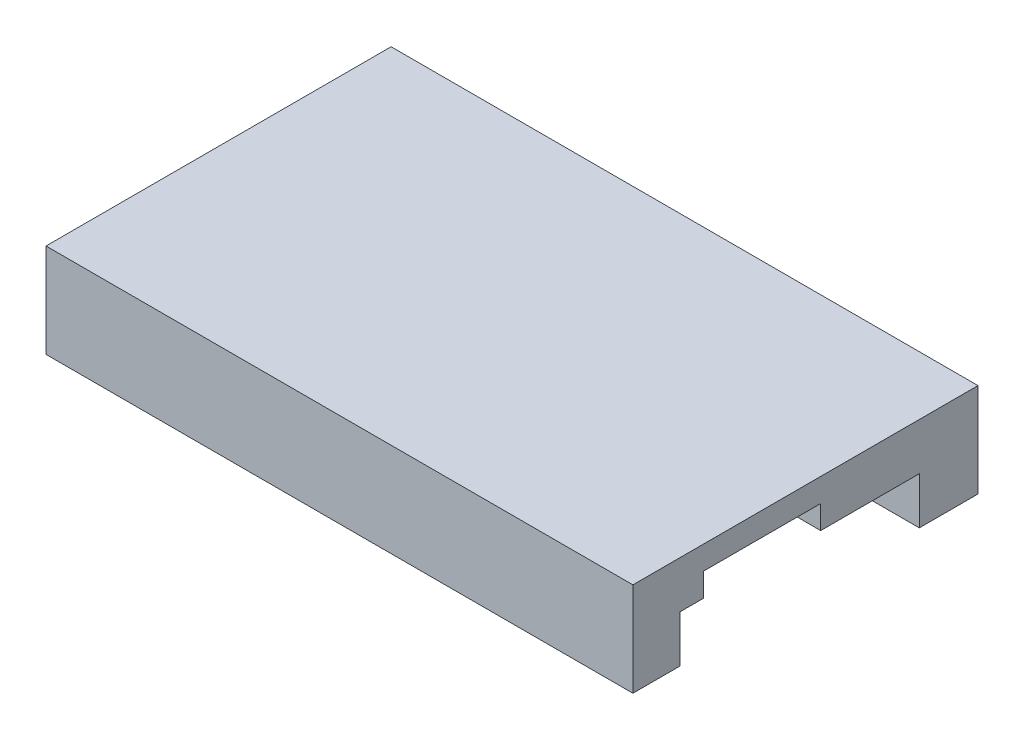
from build123d import *

# Parameters (mm, degrees)
SKETCH1_W           = 25
SKETCH1_H           = 14.7
BOSS_EXTRUDE1_DEPTH = 1
SKETCH2_W           = 5
SKETCH2_H           = 7.3
CUT_EXTRUDE1_DEPTH  = 1
SKETCH3_W           = 7.5
SKETCH3_H           = 5
CUT_EXTRUDE2_DEPTH  = 1
BOSS_EXTRUDE2_DEPTH = 1
SKETCH9_W           = 25
SKETCH9_H           = 14.7
BOSS_EXTRUDE3_DEPTH = 1
SKETCH11_W          = 22.5
SKETCH11_H          = 1
SKETCH11_W_2        = 2.5
SKETCH11_H_2        = 1.5
BOSS_EXTRUDE5_DEPTH = 1


with BuildPart() as part:
    # Sketch1 → Boss-Extrude1 (new body)
    with BuildSketch(Plane(origin=(0, 0, 0), x_dir=(1, 0, 0), z_dir=(0, 1, 0))):
        with Locations((-29.985488774, 13.606547542)):
            Rectangle(SKETCH1_W, SKETCH1_H)
    extrude(amount=BOSS_EXTRUDE1_DEPTH)

    # Sketch2 → Cut-Extrude1 (cut)
    with BuildSketch(Plane(origin=(0, 1, 0), x_dir=(1, 0, 0), z_dir=(0, 1, 0))):
        with Locations((-39.985488774, 14.606547542)):
            Rectangle(SKETCH2_W, SKETCH2_H)
    extrude(amount=-CUT_EXTRUDE1_DEPTH, mode=Mode.SUBTRACT)

    # Sketch3 → Cut-Extrude2 (cut)
    with BuildSketch(Plane(origin=(0, 1, 0), x_dir=(1, 0, 0), z_dir=(0, 1, 0))):
        with Locations((-21.235488774, 11.756547542)):
            Rectangle(SKETCH3_W, SKETCH3_H)
    extrude(amount=-CUT_EXTRUDE2_DEPTH, mode=Mode.SUBTRACT)

    # Sketch4 → Boss-Extrude2 (add)
    with BuildSketch(Plane.XZ):
        Polygon((-42.485488774, -6.256547542), (-42.485488774, -7.756547542), (-20.485488774, -7.756547542), (-20.485488774, -8.256547542), (-17.485488774, -8.256547542), (-17.485488774, -6.256547542), align=None)
        Polygon((-20.485488774, -19.456547542), (-42.485488774, -19.456547542), (-42.485488774, -20.956547542), (-17.485488774, -20.956547542), (-17.485488774, -18.456547542), (-20.485488774, -18.456547542), align=None)
    extrude(amount=BOSS_EXTRUDE2_DEPTH)

    # Sketch9 → Boss-Extrude3 (add)
    with BuildSketch(Plane(origin=(0, 1, 0), x_dir=(1, 0, 0), z_dir=(0, 1, 0))):
        with Locations((-29.985488774, 13.606547542)):
            Rectangle(SKETCH9_W, SKETCH9_H)
    extrude(amount=BOSS_EXTRUDE3_DEPTH)

    # Sketch11 → Boss-Extrude5 (add)
    with BuildSketch(Plane(origin=(0, -1, 0), x_dir=(-1, 0, 0), z_dir=(0, -1, 0))):
        with Locations((31.235488774, 6.756547542)):
            Rectangle(SKETCH11_W, SKETCH11_H)
        with Locations((18.735488774, 6.756547542)):
            Rectangle(SKETCH11_W_2, SKETCH11_H)
        with Locations((18.735488774, 7.756547542)):
            Rectangle(SKETCH11_W_2, SKETCH11_H)
        with Locations((18.735488774, 19.206547542)):
            Rectangle(SKETCH11_W_2, SKETCH11_H_2)
        with Locations((18.735488774, 20.456547542)):
            Rectangle(SKETCH11_W_2, SKETCH11_H)
        with Locations((31.235488774, 20.456547542)):
            Rectangle(SKETCH11_W, SKETCH11_H)
    extrude(amount=BOSS_EXTRUDE5_DEPTH)


solid = part.part
